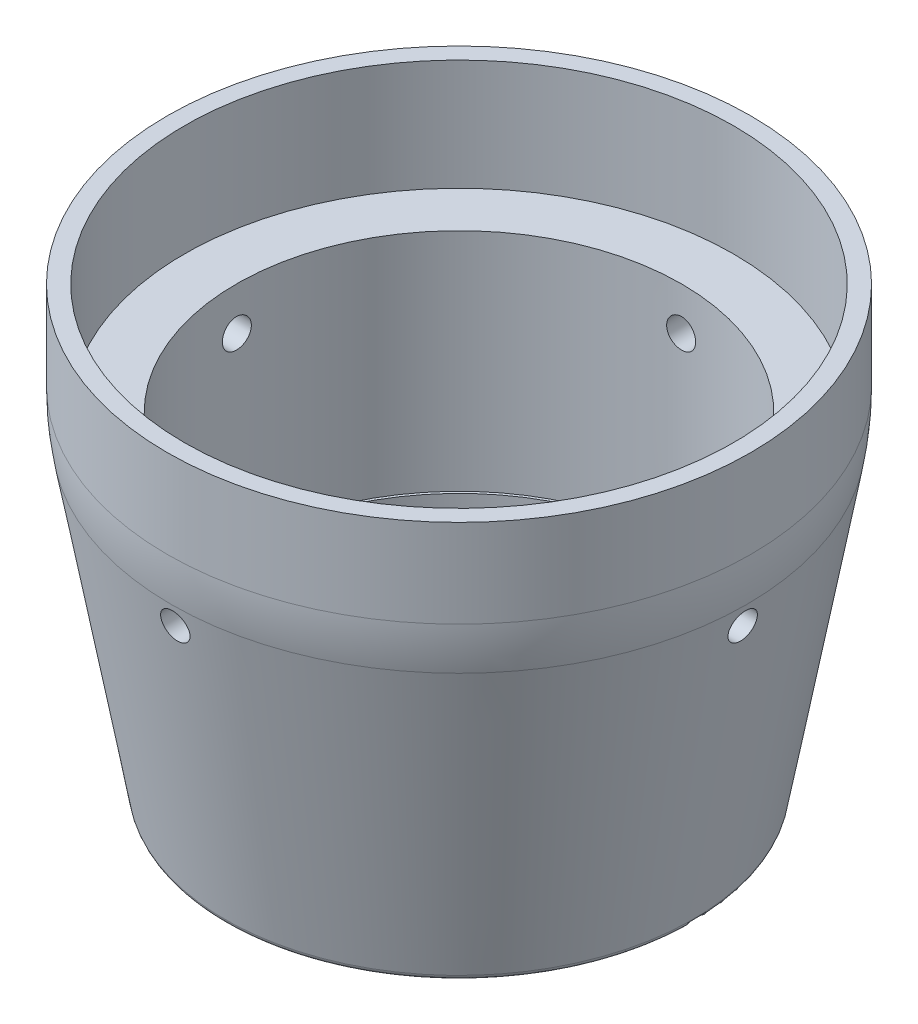
from build123d import *

# Parameters (mm, degrees)
F_6_40_TAPPED_HOLE1_REACH  = 74.325
F_6_40_TAPPED_HOLE1_BORE_R = 1.4351
CIRPATTERN1_COUNT          = 4
FILLET1_R                  = 0.635
FILLET2_R                  = 25.4


with BuildPart() as part:
    # Sketch2 → Revolve1 (revolve)
    with BuildSketch(Plane.XY, mode=Mode.PRIVATE) as revolve1_sk:
        Polygon((22.0472, -22.4282), (22.0472, -0.0762), (27.1907, -0.0762), (27.1907, 10.922), (28.8925, 10.922), (28.8925, -0.0762), (23.0632, -32.512), (21.7932, -32.512), (21.7932, -22.4282), align=None)
    revolve(revolve1_sk.sketch.rotate(Axis((0, -34.5451, 0), (0, 1, 0)), 90), axis=Axis((0, -34.5451, 0), (0, 1, 0)))

    # #6-40 Tapped Hole1 bore → #6-40 Tapped Hole1 (cut, up to next)
    with BuildSketch(Plane.XY.offset(28.8925), mode=Mode.PRIVATE) as f_6_40_tapped_hole1_sk1:
        with Locations((0, -4.318)):
            Circle(F_6_40_TAPPED_HOLE1_BORE_R)
    f_6_40_tapped_hole1_tool1 = extrude(f_6_40_tapped_hole1_sk1.sketch, amount=-F_6_40_TAPPED_HOLE1_REACH, mode=Mode.PRIVATE) & part.part
    f_6_40_tapped_hole1 = f_6_40_tapped_hole1_tool1.solids().sort_by_distance((0, -4.318, 28.8925))[0]
    add(f_6_40_tapped_hole1, mode=Mode.SUBTRACT)

    # CirPattern1: #6-40 Tapped Hole1 ×4 about axis
    cirpattern1_axis = Axis((0, -34.5451, 0), (0, -1, 0))
    for i in range(1, CIRPATTERN1_COUNT):
        add(f_6_40_tapped_hole1.rotate(cirpattern1_axis, i * 360 / CIRPATTERN1_COUNT), mode=Mode.SUBTRACT)

    # Fillet1
    fillet1_edges = [part.edges().sort_by_distance(p)[0] for p in [
        (0, -32.512, 23.0632),
    ]]
    fillet(fillet1_edges, radius=FILLET1_R)

    # Fillet2
    fillet2_edges = [part.edges().sort_by_distance(p)[0] for p in [
        (0, -0.0762, 28.8925),
    ]]
    fillet(fillet2_edges, radius=FILLET2_R)


solid = part.part
